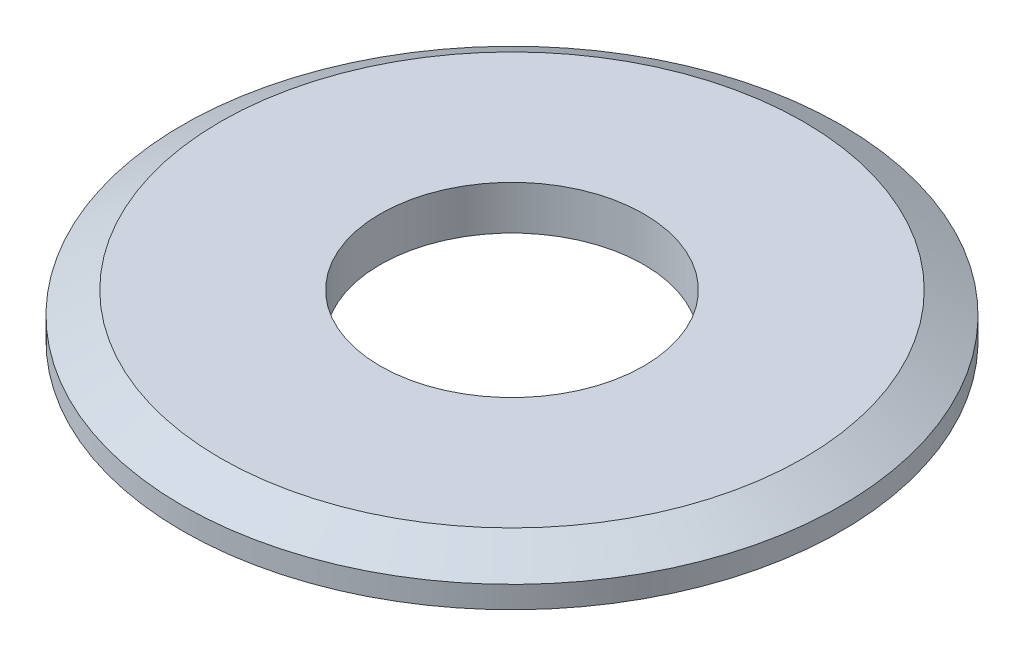
from build123d import *

# Parameters (mm, degrees)
SKETCH1_R           = 7.5
BOSS_EXTRUDE1_DEPTH = 1
CHAMFER1_SIZE       = 0.5
CHAMFER1_SIZE2      = 0.866025404
SKETCH2_R           = 3
CUT_EXTRUDE1_DEPTH  = 1


with BuildPart() as part:
    # Sketch1 → Boss-Extrude1 (new body)
    with BuildSketch(Plane(origin=(0, 0, 0), x_dir=(1, 0, 0), z_dir=(0, 1, 0))):
        Circle(SKETCH1_R)
    extrude(amount=BOSS_EXTRUDE1_DEPTH)

    # Chamfer1
    chamfer1_edges = [part.edges().sort_by_distance(p)[0] for p in [
        (-7.5, 1, 0),
    ]]
    chamfer1_side = [part.faces().sort_by_distance(p)[0] for p in [
        (-7.5, 0.5, 0),
    ]]
    chamfer(chamfer1_edges, length=CHAMFER1_SIZE, length2=CHAMFER1_SIZE2, reference=chamfer1_side[0])

    # Sketch2 → Cut-Extrude1 (cut)
    with BuildSketch(Plane(origin=(0, 1, 0), x_dir=(1, 0, 0), z_dir=(0, 1, 0))):
        Circle(SKETCH2_R)
    extrude(amount=-CUT_EXTRUDE1_DEPTH, mode=Mode.SUBTRACT)


solid = part.part
